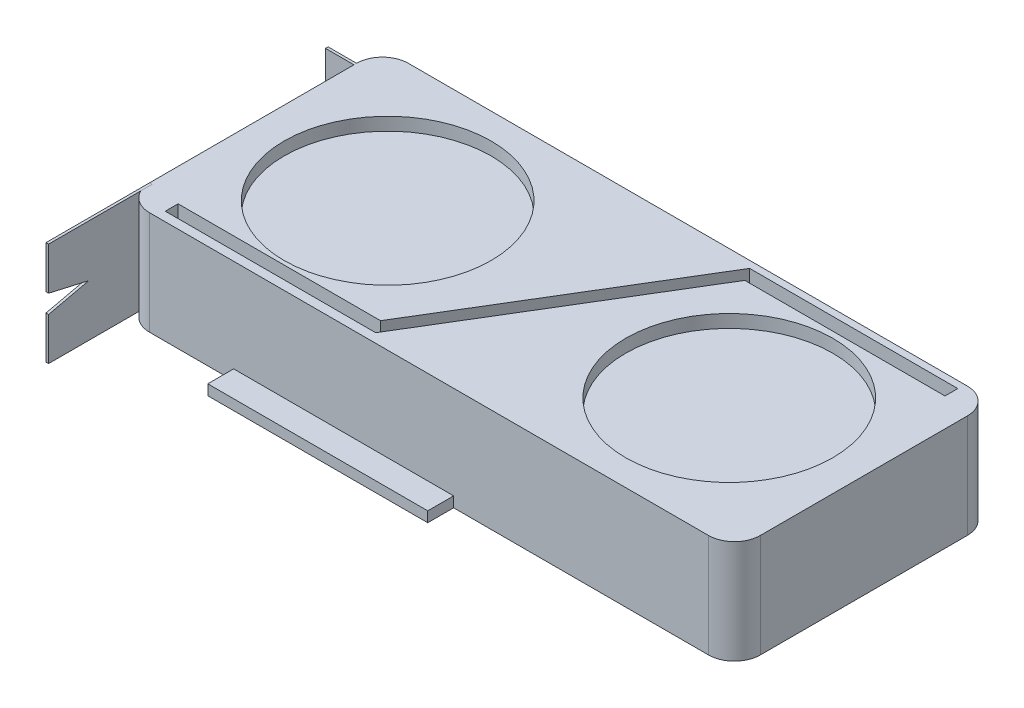
from build123d import *

# Parameters (mm, degrees)
SKETCH1_W           = 236
SKETCH1_H           = 100
BOSS_EXTRUDE1_DEPTH = 40
SKETCH2_R           = 40
CUT_EXTRUDE1_DEPTH  = 5
FILLET1_R           = 10
CUT_EXTRUDE2_DEPTH  = 10
SKETCH4_W           = 85
SKETCH4_H           = 4
BOSS_EXTRUDE2_DEPTH = 10
BOSS_EXTRUDE3_DEPTH = 1
SKETCH6_W           = 1
SKETCH6_H           = 40
BOSS_EXTRUDE4_DEPTH = 11


with BuildPart() as part:
    # Sketch1 → Boss-Extrude1 (new body)
    with BuildSketch(Plane(origin=(0, 0, 0), x_dir=(1, 0, 0), z_dir=(0, 1, 0))):
        Rectangle(SKETCH1_W, SKETCH1_H)
    extrude(amount=BOSS_EXTRUDE1_DEPTH)

    # Sketch2 → Cut-Extrude1 (cut)
    with BuildSketch(Plane(origin=(0, 40, 0), x_dir=(1, 0, 0), z_dir=(0, 1, 0))):
        with Locations((-66, 0)):
            Circle(SKETCH2_R)
        with Locations((66, 0)):
            Circle(SKETCH2_R)
    extrude(amount=-CUT_EXTRUDE1_DEPTH, mode=Mode.SUBTRACT)

    # Fillet1
    fillet1_edges = [part.edges().sort_by_distance(p)[0] for p in [
        (118, 20, 50),
        (-118, 20, 50),
        (-118, 20, -50),
        (118, 20, -50),
    ]]
    fillet(fillet1_edges, radius=FILLET1_R)

    # Sketch3 → Cut-Extrude2 (cut)
    with BuildSketch(Plane(origin=(0, 40, 0), x_dir=(1, 0, 0), z_dir=(0, 1, 0))):
        Polygon((-105.463124796, -41.502087977), (-105.463124796, -46.455012056), (-24.138936023, -46.455012056), (29.66006691, 42.356040404), (107.000239166, 42.356040404), (107.000239166, 47.308964484), (26.557920495, 47.308964484), (-27.241082437, -41.502087977), align=None)
    extrude(amount=-CUT_EXTRUDE2_DEPTH, mode=Mode.SUBTRACT)

    # Sketch4 → Boss-Extrude2 (add)
    with BuildSketch(Plane.XY.offset(50)):
        with Locations((-33, 2)):
            Rectangle(SKETCH4_W, SKETCH4_H)
    extrude(amount=BOSS_EXTRUDE2_DEPTH)

    # Sketch6 → Boss-Extrude4 (add)
    with BuildSketch(Plane.ZY.offset(118)):
        with Locations((-39.5, 20)):
            Rectangle(SKETCH6_W, SKETCH6_H)
    extrude(amount=BOSS_EXTRUDE4_DEPTH)


with BuildPart() as body_2:
    # Sketch5 → Boss-Extrude3 (new body)
    with BuildSketch(Plane.ZY.offset(118)):
        Polygon((40, 40), (80, 40), (80, 23.543767562), (64.464749099, 20), (80, 16.456232438), (80, 0), (40, 0), align=None)
    extrude(amount=-BOSS_EXTRUDE3_DEPTH)


solid = Compound([part.part, body_2.part])
